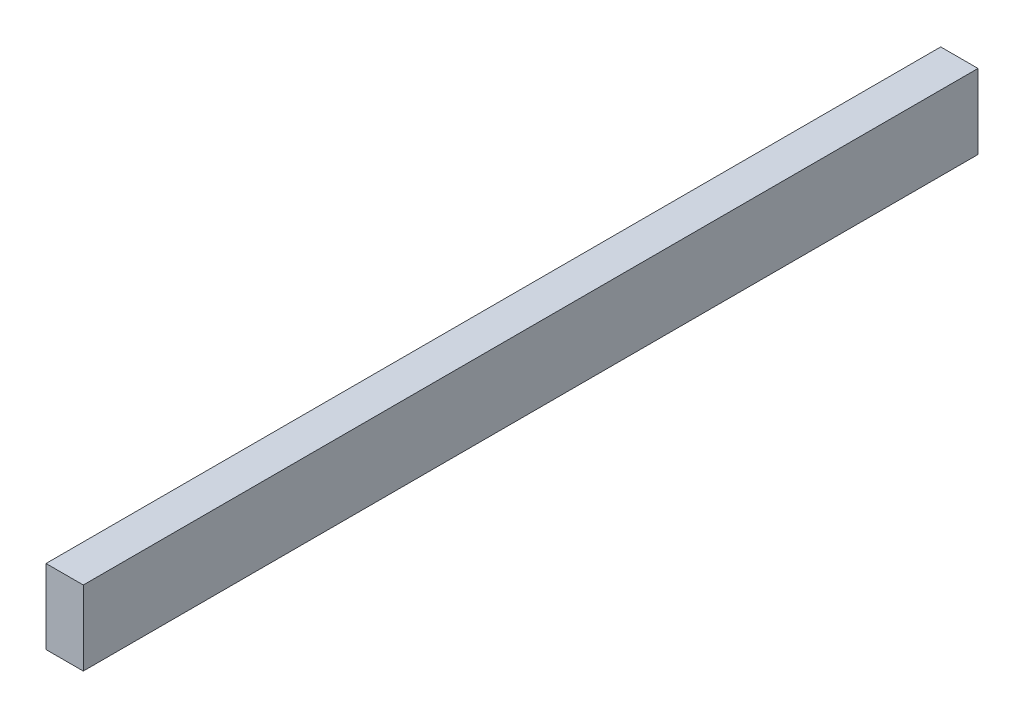
from build123d import *

# Parameters (mm, degrees)
SKETCH1_W           = 25.4
SKETCH1_H           = 609.6
BOSS_EXTRUDE1_DEPTH = 50.8


with BuildPart() as part:
    # Sketch1 → Boss-Extrude1 (new body)
    with BuildSketch(Plane(origin=(0, 0, 0), x_dir=(1, 0, 0), z_dir=(0, 1, 0))):
        with Locations((12.7, 304.8)):
            Rectangle(SKETCH1_W, SKETCH1_H)
    extrude(amount=BOSS_EXTRUDE1_DEPTH)


solid = part.part
